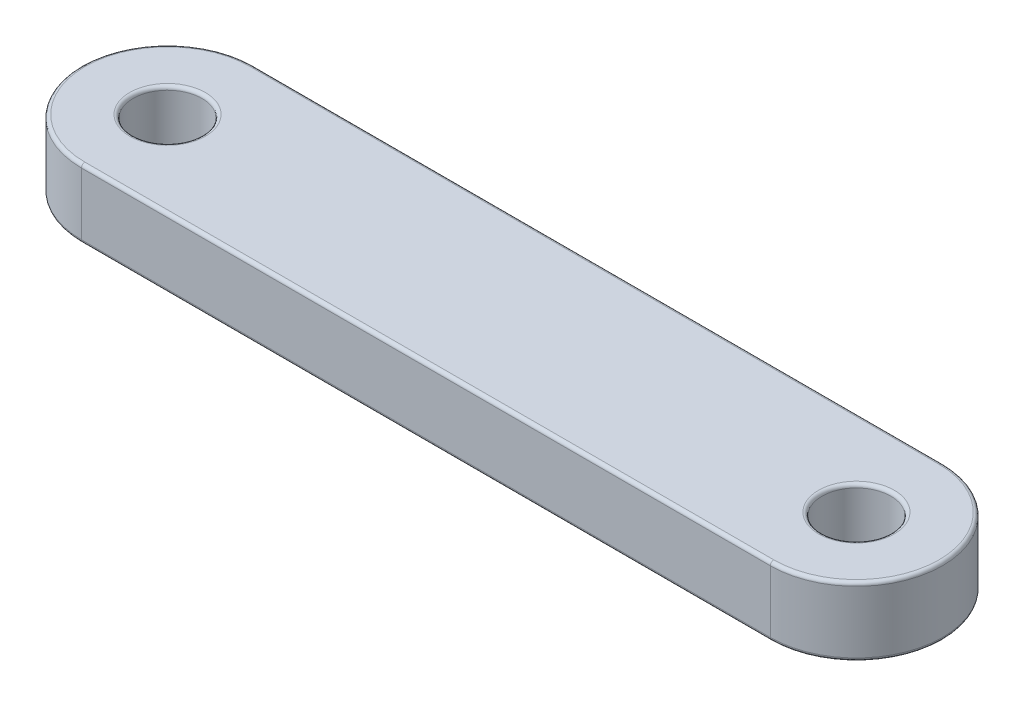
from build123d import *

# Parameters (mm, degrees)
SKETCH1_R           = 10
BOSS_EXTRUDE1_DEPTH = 20
FILLET1_R           = 1
SCALE1_SCALE        = 0.125


with BuildPart() as part:
    # Sketch1 → Boss-Extrude1 (new body)
    with BuildSketch(Plane(origin=(0, 0, 0), x_dir=(1, 0, 0), z_dir=(0, 1, 0))):
        with BuildLine():
            Line((-100, 25), (100, 25))
            ThreePointArc((100, 25), (125, 0), (100, -25))
            Line((100, -25), (-100, -25))
            ThreePointArc((-100, -25), (-125, 0), (-100, 25))
        make_face()
        with Locations((-100, 0)):
            Circle(SKETCH1_R, mode=Mode.SUBTRACT)
        with Locations((100, 0)):
            Circle(SKETCH1_R, mode=Mode.SUBTRACT)
    extrude(amount=BOSS_EXTRUDE1_DEPTH)

    # Fillet1
    fillet1_edges = [part.edges().sort_by_distance(p)[0] for p in [
        (-110, 0, 0),
        (-110, 20, 0),
        (125, 20, 0),
        (90, 0, 0),
        (90, 20, 0),
        (0, 20, -25),
        (-125, 20, 0),
        (0, 0, -25),
        (125, 0, 0),
        (0, 0, 25),
        (-125, 0, 0),
        (0, 20, 25),
    ]]
    fillet(fillet1_edges, radius=FILLET1_R)


with BuildPart() as part_1:
    # Scale1: scaled about (0, 10, 0)
    add(part.part.scale(SCALE1_SCALE).moved(Location((0, 8.75, 0))))


solid = part_1.part
